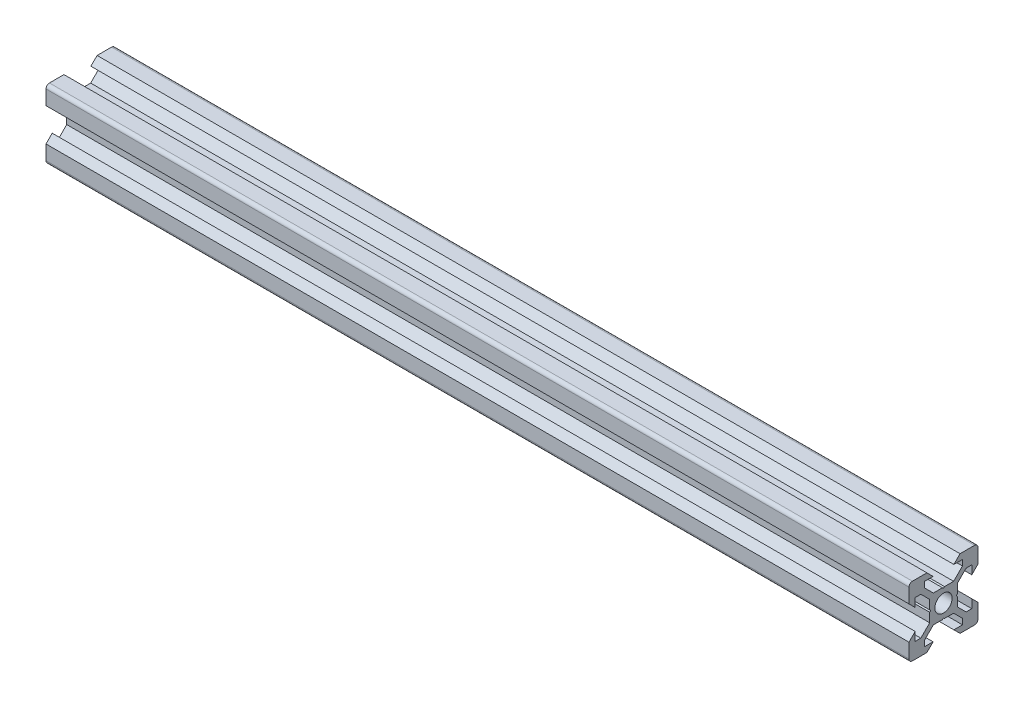
from build123d import *

# Parameters (mm, degrees)
SKETCH11_R                                  = 2.5
QUADRADO_PF20_11_PERFIL_2020_V_SLOT_1_DEPTH = 250


with BuildPart() as part:
    # Sketch11 → Quadrado PF20-11 - PERFIL 2020 V-SLOT(1) (new body)
    with BuildSketch(Plane.YZ):
        with BuildLine():
            Line((-4.8, 10), (-3, 8.2))
            Line((-3, 8.2), (-5.5, 8.2))
            Line((-5.5, 8.2), (-5.5, 6.560660172))
            Line((-5.5, 6.560660172), (-2.939339828, 4))
            Line((-2.939339828, 4), (-0.3, 4))
            Line((-0.3, 4), (0, 3.7))
            Line((0, 3.7), (0.3, 4))
            Line((0.3, 4), (2.939339828, 4))
            Line((2.939339828, 4), (5.5, 6.560660172))
            Line((5.5, 6.560660172), (5.5, 8.2))
            Line((5.5, 8.2), (3, 8.2))
            Line((3, 8.2), (4.8, 10))
            Line((4.8, 10), (9, 10))
            ThreePointArc((9, 10), (9.707106781, 9.707106781), (10, 9))
            Line((10, 9), (10, 4.8))
            Line((10, 4.8), (8.2, 3))
            Line((8.2, 3), (8.2, 5.5))
            Line((8.2, 5.5), (6.560660172, 5.5))
            Line((6.560660172, 5.5), (4, 2.939339828))
            Line((4, 2.939339828), (4, 0.3))
            Line((4, 0.3), (3.7, 0))
            Line((3.7, 0), (4, -0.3))
            Line((4, -0.3), (4, -2.939339828))
            Line((4, -2.939339828), (6.560660172, -5.5))
            Line((6.560660172, -5.5), (8.2, -5.5))
            Line((8.2, -5.5), (8.2, -3))
            Line((8.2, -3), (10, -4.8))
            Line((10, -4.8), (10, -9))
            ThreePointArc((10, -9), (9.707106781, -9.707106781), (9, -10))
            Line((9, -10), (4.8, -10))
            Line((4.8, -10), (3, -8.2))
            Line((3, -8.2), (5.5, -8.2))
            Line((5.5, -8.2), (5.5, -6.560660172))
            Line((5.5, -6.560660172), (2.939339828, -4))
            Line((2.939339828, -4), (0.3, -4))
            Line((0.3, -4), (0, -3.7))
            Line((0, -3.7), (-0.3, -4))
            Line((-0.3, -4), (-2.939339828, -4))
            Line((-2.939339828, -4), (-5.5, -6.560660172))
            Line((-5.5, -6.560660172), (-5.5, -8.2))
            Line((-5.5, -8.2), (-3, -8.2))
            Line((-3, -8.2), (-4.8, -10))
            Line((-4.8, -10), (-9, -10))
            ThreePointArc((-9, -10), (-9.707106781, -9.707106781), (-10, -9))
            Line((-10, -9), (-10, -4.8))
            Line((-10, -4.8), (-8.2, -3))
            Line((-8.2, -3), (-8.2, -5.5))
            Line((-8.2, -5.5), (-6.560660172, -5.5))
            Line((-6.560660172, -5.5), (-4, -2.939339828))
            Line((-4, -2.939339828), (-4, -0.3))
            Line((-4, -0.3), (-3.7, 0))
            Line((-3.7, 0), (-4, 0.3))
            Line((-4, 0.3), (-4, 2.939339828))
            Line((-4, 2.939339828), (-6.560660172, 5.5))
            Line((-6.560660172, 5.5), (-8.2, 5.5))
            Line((-8.2, 5.5), (-8.2, 3))
            Line((-8.2, 3), (-10, 4.8))
            Line((-10, 4.8), (-10, 9))
            ThreePointArc((-10, 9), (-9.707106781, 9.707106781), (-9, 10))
            Line((-9, 10), (-4.8, 10))
        make_face()
        Circle(SKETCH11_R, mode=Mode.SUBTRACT)
    extrude(amount=QUADRADO_PF20_11_PERFIL_2020_V_SLOT_1_DEPTH)


solid = part.part
